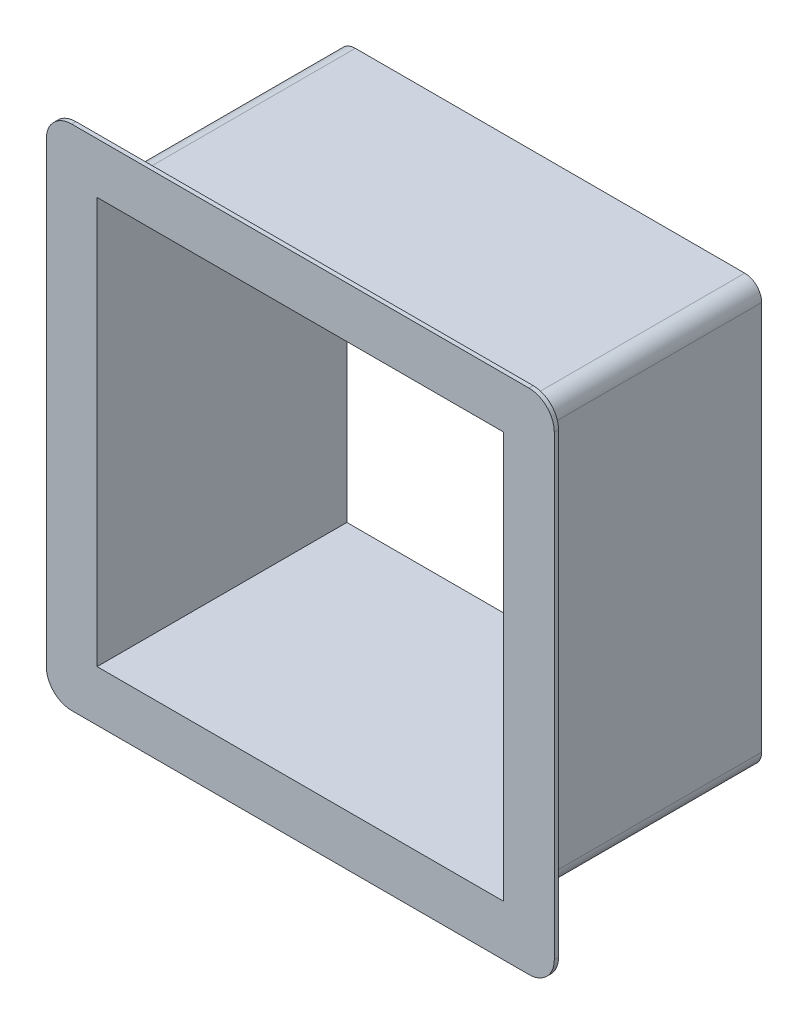
from build123d import *

# Parameters (mm, degrees)
SKETCH1_W           = 100
SKETCH1_H           = 100
SKETCH1_W_2         = 96
SKETCH1_H_2         = 96
BOSS_EXTRUDE1_DEPTH = 59
SKETCH2_W           = 120
SKETCH2_H           = 120
SKETCH2_W_2         = 100
SKETCH2_H_2         = 100
BOSS_EXTRUDE4_DEPTH = 1
FILLET1_R           = 4
FILLET2_R           = 6


with BuildPart() as part:
    # Sketch1 → Boss-Extrude1 (new body)
    with BuildSketch(Plane.XY):
        Rectangle(SKETCH1_W, SKETCH1_H)
        Rectangle(SKETCH1_W_2, SKETCH1_H_2, mode=Mode.SUBTRACT)
    extrude(amount=-BOSS_EXTRUDE1_DEPTH)

    # Sketch2 → Boss-Extrude4 (add)
    with BuildSketch(Plane.XY):
        Rectangle(SKETCH2_W, SKETCH2_H)
        Rectangle(SKETCH2_W_2, SKETCH2_H_2, mode=Mode.SUBTRACT)
    extrude(amount=-BOSS_EXTRUDE4_DEPTH)

    # Fillet1
    fillet1_edges = [part.edges().sort_by_distance(p)[0] for p in [
        (-50, -50, -30),
        (-50, 50, -30),
        (50, 50, -30),
        (50, -50, -30),
    ]]
    fillet(fillet1_edges, radius=FILLET1_R)

    # Fillet2
    fillet2_edges = [part.edges().sort_by_distance(p)[0] for p in [
        (60, -60, -0.5),
        (-60, -60, -0.5),
        (-60, 60, -0.5),
        (60, 60, -0.5),
    ]]
    fillet(fillet2_edges, radius=FILLET2_R)


solid = part.part
